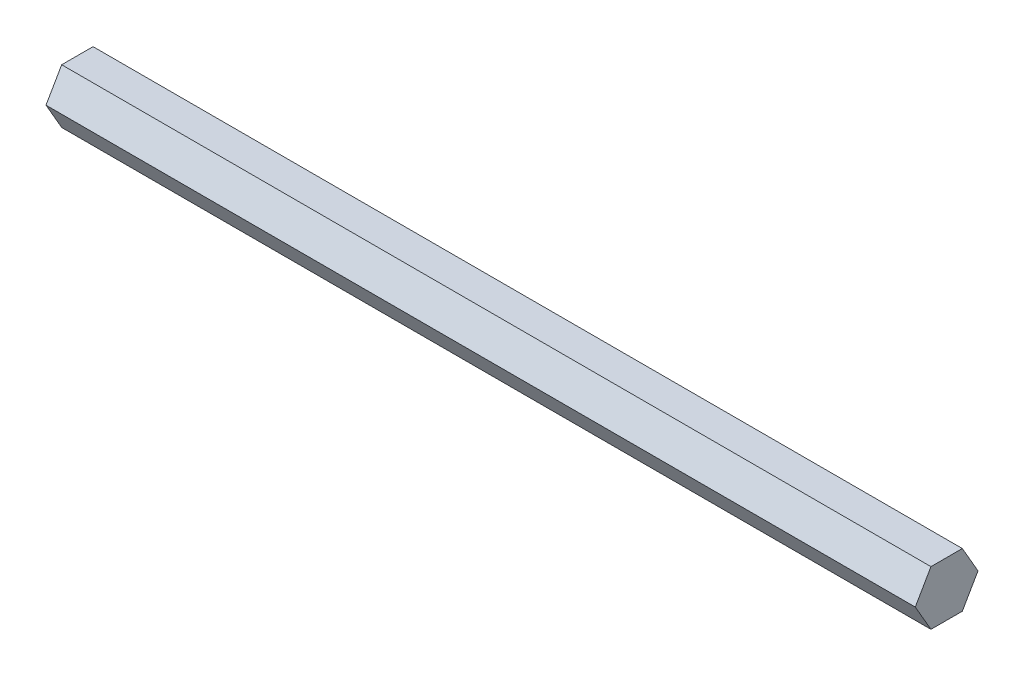
from build123d import *

# Parameters (mm, degrees)
BOSS_EXTRUDE1_DEPTH = 203.2


with BuildPart() as part:
    # Sketch1 → Boss-Extrude1 (new body)
    with BuildSketch(Plane(origin=(0, 0, 0), x_dir=(0, 0, -1), z_dir=(1, 0, 0))):
        Polygon((7.332348419, 0), (3.666174209, 6.35), (-3.666174209, 6.35), (-7.332348419, 0), (-3.666174209, -6.35), (3.666174209, -6.35), align=None)
    extrude(amount=BOSS_EXTRUDE1_DEPTH)


solid = part.part
